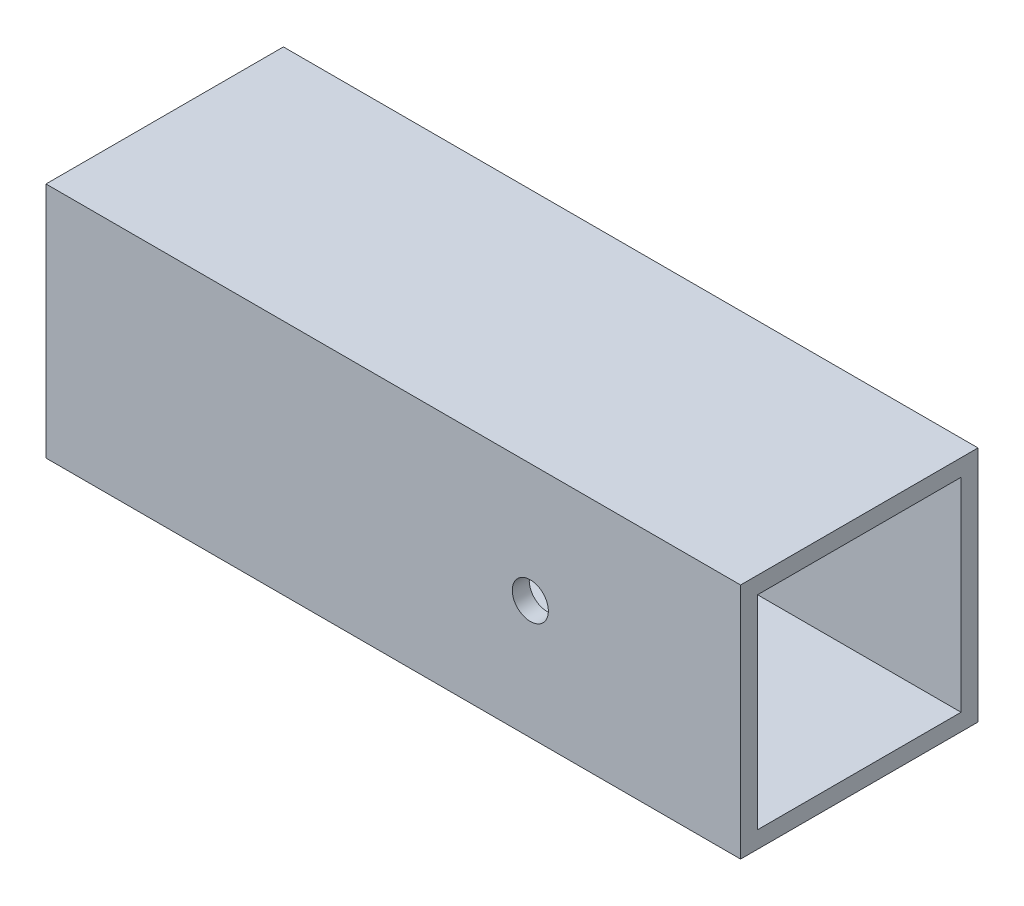
from build123d import *

# Parameters (mm, degrees)
SKETCH2_W               = 44.45
SKETCH2_H               = 44.45
SKETCH2_W_2             = 38.1
SKETCH2_H_2             = 38.1
BOSS_EXTRUDE1_DEPTH     = 130.048
F_1_4_CLEARANCE_HOLE1_D = 6.7564


with BuildPart() as part:
    # Sketch2 → Boss-Extrude1 (new body)
    with BuildSketch(Plane(origin=(0, 0, 0), x_dir=(0, 0, -1), z_dir=(1, 0, 0))):
        with Locations((22.225, 22.225)):
            Rectangle(SKETCH2_W, SKETCH2_H)
        with Locations((22.225, 22.225)):
            Rectangle(SKETCH2_W_2, SKETCH2_H_2, mode=Mode.SUBTRACT)
    extrude(amount=BOSS_EXTRUDE1_DEPTH)

    # 1/4 Clearance Hole1 (through all)
    with Locations(Plane.XY):
        with Locations((90.678, 22.225)):
            Hole(F_1_4_CLEARANCE_HOLE1_D / 2)


solid = part.part
